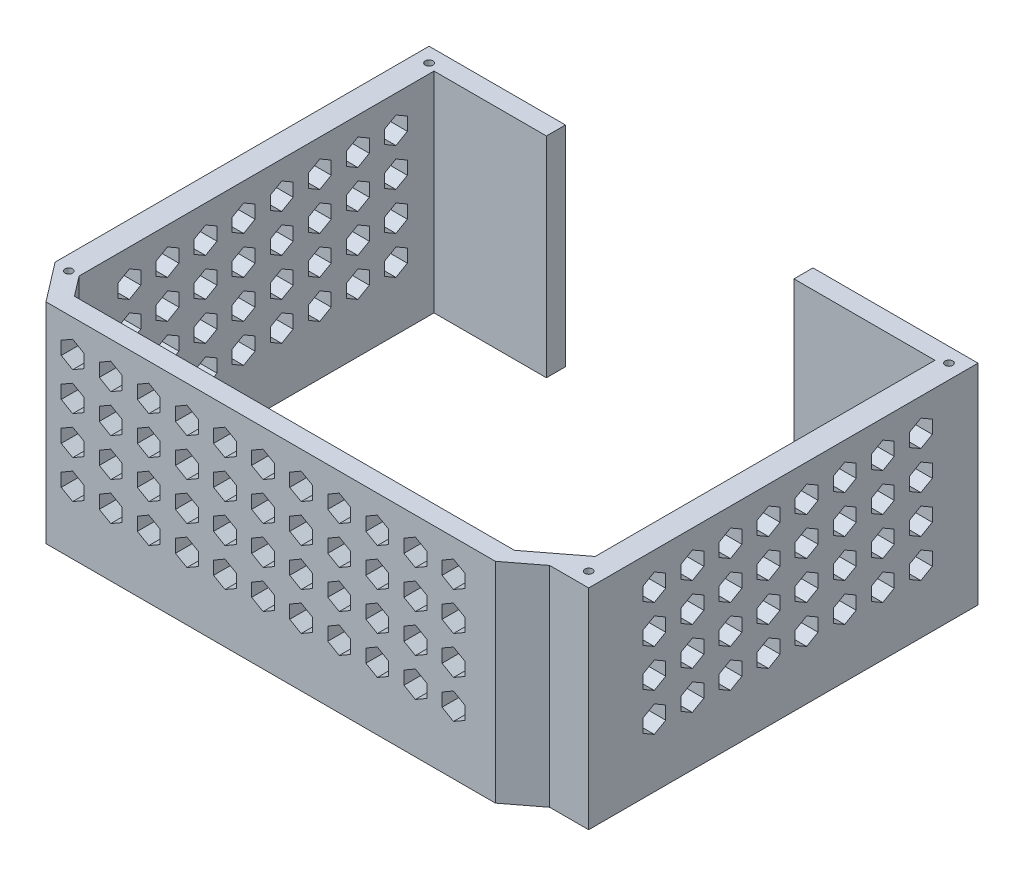
from build123d import *

# Parameters (mm, degrees)
SKETCH1_R           = 1
BOSS_EXTRUDE1_DEPTH = 55
CUT_EXTRUDE1_DEPTH  = 5
CUT_EXTRUDE2_DEPTH  = 145.145


with BuildPart() as part:
    # Sketch1 → Boss-Extrude1 (new body)
    with BuildSketch(Plane(origin=(0, 0, 0), x_dir=(1, 0, 0), z_dir=(0, 1, 0))):
        Polygon((-3.815, 98.425), (-3.815, 0.218180503), (4.017753579, -10), (122.03, -10), (130.098611603, -3.815), (140.33, -3.815), (140.33, 98.425), (97, 98.425), (97, 93.425), (134.03, 93.425), (134.03, 4.19860859), (122.03, -5), (6.485, -5), (2.485, 0.218180503), (2.485, 93.425), (32, 93.425), (32, 98.425), align=None)
        Circle(SKETCH1_R, mode=Mode.SUBTRACT)
        with Locations((136.52, 0)):
            Circle(SKETCH1_R, mode=Mode.SUBTRACT)
        with Locations((136.52, 94.61)):
            Circle(SKETCH1_R, mode=Mode.SUBTRACT)
        with Locations((0, 94.61)):
            Circle(SKETCH1_R, mode=Mode.SUBTRACT)
    extrude(amount=BOSS_EXTRUDE1_DEPTH)

    # Sketch2 → Cut-Extrude1 (cut)
    with BuildSketch(Plane.XY.offset(10)):
        Polygon((11.017753579, 43.07179677), (14.017753579, 44.803847577), (14.017753579, 48.267949192), (11.017753579, 50), (8.017753579, 48.267949192), (8.017753579, 44.803847577), align=None)
        Polygon((21.017753579, 43.07179677), (24.017753579, 44.803847577), (24.017753579, 48.267949192), (21.017753579, 50), (18.017753579, 48.267949192), (18.017753579, 44.803847577), align=None)
        Polygon((31.017753579, 43.07179677), (34.017753579, 44.803847577), (34.017753579, 48.267949192), (31.017753579, 50), (28.017753579, 48.267949192), (28.017753579, 44.803847577), align=None)
        Polygon((41.017753579, 43.07179677), (44.017753579, 44.803847577), (44.017753579, 48.267949192), (41.017753579, 50), (38.017753579, 48.267949192), (38.017753579, 44.803847577), align=None)
        Polygon((51.017753579, 43.07179677), (54.017753579, 44.803847577), (54.017753579, 48.267949192), (51.017753579, 50), (48.017753579, 48.267949192), (48.017753579, 44.803847577), align=None)
        Polygon((61.017753579, 43.07179677), (64.017753579, 44.803847577), (64.017753579, 48.267949192), (61.017753579, 50), (58.017753579, 48.267949192), (58.017753579, 44.803847577), align=None)
        Polygon((71.017753579, 43.07179677), (74.017753579, 44.803847577), (74.017753579, 48.267949192), (71.017753579, 50), (68.017753579, 48.267949192), (68.017753579, 44.803847577), align=None)
        Polygon((81.017753579, 43.07179677), (84.017753579, 44.803847577), (84.017753579, 48.267949192), (81.017753579, 50), (78.017753579, 48.267949192), (78.017753579, 44.803847577), align=None)
        Polygon((91.017753579, 43.07179677), (94.017753579, 44.803847577), (94.017753579, 48.267949192), (91.017753579, 50), (88.017753579, 48.267949192), (88.017753579, 44.803847577), align=None)
        Polygon((101.017753579, 43.07179677), (104.017753579, 44.803847577), (104.017753579, 48.267949192), (101.017753579, 50), (98.017753579, 48.267949192), (98.017753579, 44.803847577), align=None)
        Polygon((111.017753579, 43.07179677), (114.017753579, 44.803847577), (114.017753579, 48.267949192), (111.017753579, 50), (108.017753579, 48.267949192), (108.017753579, 44.803847577), align=None)
        Polygon((21.017753579, 33.07179677), (24.017753579, 34.803847577), (24.017753579, 38.267949192), (21.017753579, 40), (18.017753579, 38.267949192), (18.017753579, 34.803847577), align=None)
        Polygon((31.017753579, 33.07179677), (34.017753579, 34.803847577), (34.017753579, 38.267949192), (31.017753579, 40), (28.017753579, 38.267949192), (28.017753579, 34.803847577), align=None)
        Polygon((41.017753579, 33.07179677), (44.017753579, 34.803847577), (44.017753579, 38.267949192), (41.017753579, 40), (38.017753579, 38.267949192), (38.017753579, 34.803847577), align=None)
        Polygon((51.017753579, 33.07179677), (54.017753579, 34.803847577), (54.017753579, 38.267949192), (51.017753579, 40), (48.017753579, 38.267949192), (48.017753579, 34.803847577), align=None)
        Polygon((61.017753579, 33.07179677), (64.017753579, 34.803847577), (64.017753579, 38.267949192), (61.017753579, 40), (58.017753579, 38.267949192), (58.017753579, 34.803847577), align=None)
        Polygon((71.017753579, 33.07179677), (74.017753579, 34.803847577), (74.017753579, 38.267949192), (71.017753579, 40), (68.017753579, 38.267949192), (68.017753579, 34.803847577), align=None)
        Polygon((81.017753579, 33.07179677), (84.017753579, 34.803847577), (84.017753579, 38.267949192), (81.017753579, 40), (78.017753579, 38.267949192), (78.017753579, 34.803847577), align=None)
        Polygon((91.017753579, 33.07179677), (94.017753579, 34.803847577), (94.017753579, 38.267949192), (91.017753579, 40), (88.017753579, 38.267949192), (88.017753579, 34.803847577), align=None)
        Polygon((101.017753579, 33.07179677), (104.017753579, 34.803847577), (104.017753579, 38.267949192), (101.017753579, 40), (98.017753579, 38.267949192), (98.017753579, 34.803847577), align=None)
        Polygon((111.017753579, 33.07179677), (114.017753579, 34.803847577), (114.017753579, 38.267949192), (111.017753579, 40), (108.017753579, 38.267949192), (108.017753579, 34.803847577), align=None)
        Polygon((21.017753579, 23.07179677), (24.017753579, 24.803847577), (24.017753579, 28.267949192), (21.017753579, 30), (18.017753579, 28.267949192), (18.017753579, 24.803847577), align=None)
        Polygon((31.017753579, 23.07179677), (34.017753579, 24.803847577), (34.017753579, 28.267949192), (31.017753579, 30), (28.017753579, 28.267949192), (28.017753579, 24.803847577), align=None)
        Polygon((41.017753579, 23.07179677), (44.017753579, 24.803847577), (44.017753579, 28.267949192), (41.017753579, 30), (38.017753579, 28.267949192), (38.017753579, 24.803847577), align=None)
        Polygon((51.017753579, 23.07179677), (54.017753579, 24.803847577), (54.017753579, 28.267949192), (51.017753579, 30), (48.017753579, 28.267949192), (48.017753579, 24.803847577), align=None)
        Polygon((61.017753579, 23.07179677), (64.017753579, 24.803847577), (64.017753579, 28.267949192), (61.017753579, 30), (58.017753579, 28.267949192), (58.017753579, 24.803847577), align=None)
        Polygon((71.017753579, 23.07179677), (74.017753579, 24.803847577), (74.017753579, 28.267949192), (71.017753579, 30), (68.017753579, 28.267949192), (68.017753579, 24.803847577), align=None)
        Polygon((81.017753579, 23.07179677), (84.017753579, 24.803847577), (84.017753579, 28.267949192), (81.017753579, 30), (78.017753579, 28.267949192), (78.017753579, 24.803847577), align=None)
        Polygon((91.017753579, 23.07179677), (94.017753579, 24.803847577), (94.017753579, 28.267949192), (91.017753579, 30), (88.017753579, 28.267949192), (88.017753579, 24.803847577), align=None)
        Polygon((101.017753579, 23.07179677), (104.017753579, 24.803847577), (104.017753579, 28.267949192), (101.017753579, 30), (98.017753579, 28.267949192), (98.017753579, 24.803847577), align=None)
        Polygon((111.017753579, 23.07179677), (114.017753579, 24.803847577), (114.017753579, 28.267949192), (111.017753579, 30), (108.017753579, 28.267949192), (108.017753579, 24.803847577), align=None)
        Polygon((21.017753579, 13.07179677), (24.017753579, 14.803847577), (24.017753579, 18.267949192), (21.017753579, 20), (18.017753579, 18.267949192), (18.017753579, 14.803847577), align=None)
        Polygon((31.017753579, 13.07179677), (34.017753579, 14.803847577), (34.017753579, 18.267949192), (31.017753579, 20), (28.017753579, 18.267949192), (28.017753579, 14.803847577), align=None)
        Polygon((41.017753579, 13.07179677), (44.017753579, 14.803847577), (44.017753579, 18.267949192), (41.017753579, 20), (38.017753579, 18.267949192), (38.017753579, 14.803847577), align=None)
        Polygon((51.017753579, 13.07179677), (54.017753579, 14.803847577), (54.017753579, 18.267949192), (51.017753579, 20), (48.017753579, 18.267949192), (48.017753579, 14.803847577), align=None)
        Polygon((61.017753579, 13.07179677), (64.017753579, 14.803847577), (64.017753579, 18.267949192), (61.017753579, 20), (58.017753579, 18.267949192), (58.017753579, 14.803847577), align=None)
        Polygon((71.017753579, 13.07179677), (74.017753579, 14.803847577), (74.017753579, 18.267949192), (71.017753579, 20), (68.017753579, 18.267949192), (68.017753579, 14.803847577), align=None)
        Polygon((81.017753579, 13.07179677), (84.017753579, 14.803847577), (84.017753579, 18.267949192), (81.017753579, 20), (78.017753579, 18.267949192), (78.017753579, 14.803847577), align=None)
        Polygon((91.017753579, 13.07179677), (94.017753579, 14.803847577), (94.017753579, 18.267949192), (91.017753579, 20), (88.017753579, 18.267949192), (88.017753579, 14.803847577), align=None)
        Polygon((101.017753579, 13.07179677), (104.017753579, 14.803847577), (104.017753579, 18.267949192), (101.017753579, 20), (98.017753579, 18.267949192), (98.017753579, 14.803847577), align=None)
        Polygon((111.017753579, 13.07179677), (114.017753579, 14.803847577), (114.017753579, 18.267949192), (111.017753579, 20), (108.017753579, 18.267949192), (108.017753579, 14.803847577), align=None)
        Polygon((11.017753579, 33.07179677), (14.017753579, 34.803847577), (14.017753579, 38.267949192), (11.017753579, 40), (8.017753579, 38.267949192), (8.017753579, 34.803847577), align=None)
        Polygon((11.017753579, 23.07179677), (14.017753579, 24.803847577), (14.017753579, 28.267949192), (11.017753579, 30), (8.017753579, 28.267949192), (8.017753579, 24.803847577), align=None)
        Polygon((11.017753579, 13.07179677), (14.017753579, 14.803847577), (14.017753579, 18.267949192), (11.017753579, 20), (8.017753579, 18.267949192), (8.017753579, 14.803847577), align=None)
    extrude(amount=-CUT_EXTRUDE1_DEPTH, mode=Mode.SUBTRACT)

    # Sketch3 → Cut-Extrude2 (cut, through all)
    with BuildSketch(Plane.ZY.offset(3.815)):
        Polygon((-83.425, 43.07179677), (-80.425, 44.803847577), (-80.425, 48.267949192), (-83.425, 50), (-86.425, 48.267949192), (-86.425, 44.803847577), align=None)
        Polygon((-73.425, 43.07179677), (-70.425, 44.803847577), (-70.425, 48.267949192), (-73.425, 50), (-76.425, 48.267949192), (-76.425, 44.803847577), align=None)
        Polygon((-63.425, 43.07179677), (-60.425, 44.803847577), (-60.425, 48.267949192), (-63.425, 50), (-66.425, 48.267949192), (-66.425, 44.803847577), align=None)
        Polygon((-53.425, 43.07179677), (-50.425, 44.803847577), (-50.425, 48.267949192), (-53.425, 50), (-56.425, 48.267949192), (-56.425, 44.803847577), align=None)
        Polygon((-43.425, 43.07179677), (-40.425, 44.803847577), (-40.425, 48.267949192), (-43.425, 50), (-46.425, 48.267949192), (-46.425, 44.803847577), align=None)
        Polygon((-33.425, 43.07179677), (-30.425, 44.803847577), (-30.425, 48.267949192), (-33.425, 50), (-36.425, 48.267949192), (-36.425, 44.803847577), align=None)
        Polygon((-23.425, 43.07179677), (-20.425, 44.803847577), (-20.425, 48.267949192), (-23.425, 50), (-26.425, 48.267949192), (-26.425, 44.803847577), align=None)
        Polygon((-13.425, 43.07179677), (-10.425, 44.803847577), (-10.425, 48.267949192), (-13.425, 50), (-16.425, 48.267949192), (-16.425, 44.803847577), align=None)
        Polygon((-73.425, 33.07179677), (-70.425, 34.803847577), (-70.425, 38.267949192), (-73.425, 40), (-76.425, 38.267949192), (-76.425, 34.803847577), align=None)
        Polygon((-63.425, 33.07179677), (-60.425, 34.803847577), (-60.425, 38.267949192), (-63.425, 40), (-66.425, 38.267949192), (-66.425, 34.803847577), align=None)
        Polygon((-53.425, 33.07179677), (-50.425, 34.803847577), (-50.425, 38.267949192), (-53.425, 40), (-56.425, 38.267949192), (-56.425, 34.803847577), align=None)
        Polygon((-43.425, 33.07179677), (-40.425, 34.803847577), (-40.425, 38.267949192), (-43.425, 40), (-46.425, 38.267949192), (-46.425, 34.803847577), align=None)
        Polygon((-33.425, 33.07179677), (-30.425, 34.803847577), (-30.425, 38.267949192), (-33.425, 40), (-36.425, 38.267949192), (-36.425, 34.803847577), align=None)
        Polygon((-23.425, 33.07179677), (-20.425, 34.803847577), (-20.425, 38.267949192), (-23.425, 40), (-26.425, 38.267949192), (-26.425, 34.803847577), align=None)
        Polygon((-13.425, 33.07179677), (-10.425, 34.803847577), (-10.425, 38.267949192), (-13.425, 40), (-16.425, 38.267949192), (-16.425, 34.803847577), align=None)
        Polygon((-73.425, 23.07179677), (-70.425, 24.803847577), (-70.425, 28.267949192), (-73.425, 30), (-76.425, 28.267949192), (-76.425, 24.803847577), align=None)
        Polygon((-63.425, 23.07179677), (-60.425, 24.803847577), (-60.425, 28.267949192), (-63.425, 30), (-66.425, 28.267949192), (-66.425, 24.803847577), align=None)
        Polygon((-53.425, 23.07179677), (-50.425, 24.803847577), (-50.425, 28.267949192), (-53.425, 30), (-56.425, 28.267949192), (-56.425, 24.803847577), align=None)
        Polygon((-43.425, 23.07179677), (-40.425, 24.803847577), (-40.425, 28.267949192), (-43.425, 30), (-46.425, 28.267949192), (-46.425, 24.803847577), align=None)
        Polygon((-33.425, 23.07179677), (-30.425, 24.803847577), (-30.425, 28.267949192), (-33.425, 30), (-36.425, 28.267949192), (-36.425, 24.803847577), align=None)
        Polygon((-23.425, 23.07179677), (-20.425, 24.803847577), (-20.425, 28.267949192), (-23.425, 30), (-26.425, 28.267949192), (-26.425, 24.803847577), align=None)
        Polygon((-13.425, 23.07179677), (-10.425, 24.803847577), (-10.425, 28.267949192), (-13.425, 30), (-16.425, 28.267949192), (-16.425, 24.803847577), align=None)
        Polygon((-73.425, 13.07179677), (-70.425, 14.803847577), (-70.425, 18.267949192), (-73.425, 20), (-76.425, 18.267949192), (-76.425, 14.803847577), align=None)
        Polygon((-63.425, 13.07179677), (-60.425, 14.803847577), (-60.425, 18.267949192), (-63.425, 20), (-66.425, 18.267949192), (-66.425, 14.803847577), align=None)
        Polygon((-53.425, 13.07179677), (-50.425, 14.803847577), (-50.425, 18.267949192), (-53.425, 20), (-56.425, 18.267949192), (-56.425, 14.803847577), align=None)
        Polygon((-43.425, 13.07179677), (-40.425, 14.803847577), (-40.425, 18.267949192), (-43.425, 20), (-46.425, 18.267949192), (-46.425, 14.803847577), align=None)
        Polygon((-33.425, 13.07179677), (-30.425, 14.803847577), (-30.425, 18.267949192), (-33.425, 20), (-36.425, 18.267949192), (-36.425, 14.803847577), align=None)
        Polygon((-23.425, 13.07179677), (-20.425, 14.803847577), (-20.425, 18.267949192), (-23.425, 20), (-26.425, 18.267949192), (-26.425, 14.803847577), align=None)
        Polygon((-13.425, 13.07179677), (-10.425, 14.803847577), (-10.425, 18.267949192), (-13.425, 20), (-16.425, 18.267949192), (-16.425, 14.803847577), align=None)
        Polygon((-83.425, 33.07179677), (-80.425, 34.803847577), (-80.425, 38.267949192), (-83.425, 40), (-86.425, 38.267949192), (-86.425, 34.803847577), align=None)
        Polygon((-83.425, 23.07179677), (-80.425, 24.803847577), (-80.425, 28.267949192), (-83.425, 30), (-86.425, 28.267949192), (-86.425, 24.803847577), align=None)
        Polygon((-83.425, 13.07179677), (-80.425, 14.803847577), (-80.425, 18.267949192), (-83.425, 20), (-86.425, 18.267949192), (-86.425, 14.803847577), align=None)
    extrude(amount=-CUT_EXTRUDE2_DEPTH, mode=Mode.SUBTRACT)


solid = part.part
